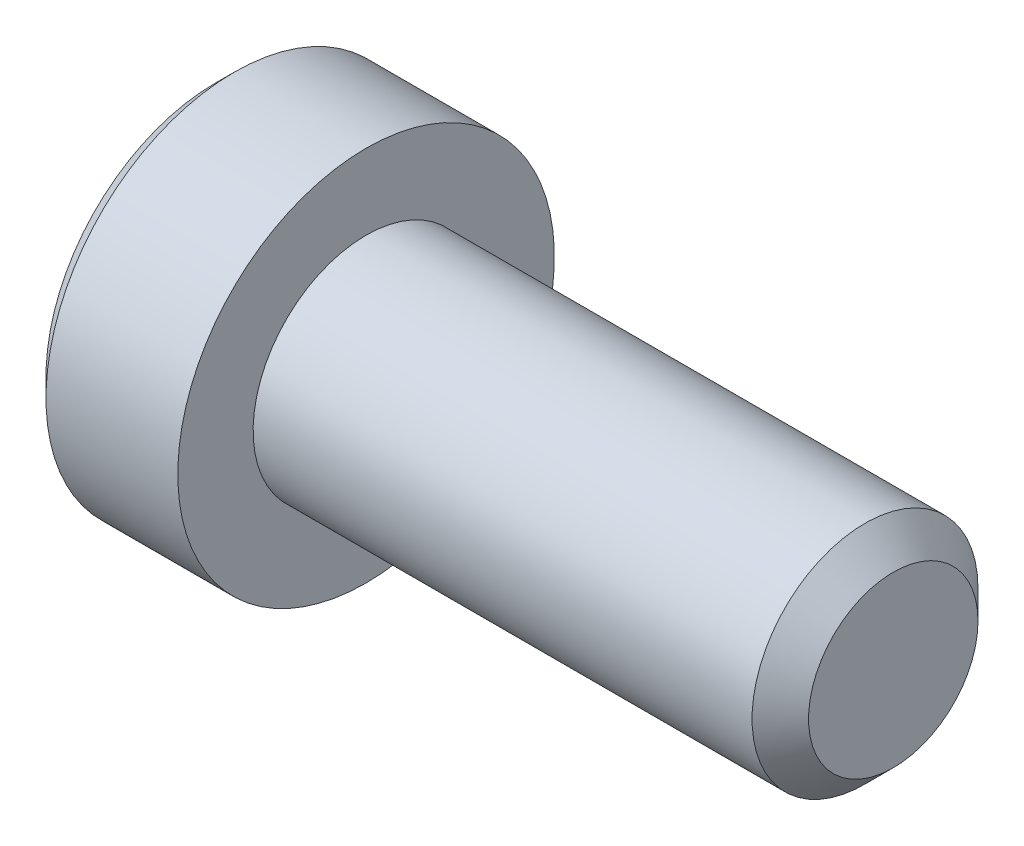
from build123d import *

# Parameters (mm, degrees)
SKETCH2_R           = 3
BOSS_EXTRUDE1_DEPTH = 14
CHAMFER1_SIZE       = 0.75
CUT_EXTRUDE1_DEPTH  = 3.12


with BuildPart() as part:
    # Sketch2 → Boss-Extrude1 (new body)
    with BuildSketch(Plane(origin=(7, 0, 0), x_dir=(0, 0, -1), z_dir=(1, 0, 0))):
        Circle(SKETCH2_R)
    extrude(amount=-BOSS_EXTRUDE1_DEPTH)

    # Chamfer1
    chamfer1_edges = [part.edges().sort_by_distance(p)[0] for p in [
        (7, 0, 3),
    ]]
    chamfer(chamfer1_edges, length=CHAMFER1_SIZE)

    # Sketch6 → Revolve1 (revolve)
    with BuildSketch(Plane.XY):
        Polygon((-10.5, 5), (-11, 4.5), (-11, 0), (-7, 0), (-7, 5), align=None)
    revolve(axis=Axis((-7, 0, 0), (-1, 0, 0)))

    # Sketch4 → Cut-Extrude1 (cut)
    with BuildSketch(Plane(origin=(-11, 0, 0), x_dir=(0, 0, -1), z_dir=(1, 0, 0))):
        Polygon((0, 2.309401077), (-2, 1.154700538), (-2, -1.154700538), (0, -2.309401077), (2, -1.154700538), (2, 1.154700538), align=None)
    extrude(amount=CUT_EXTRUDE1_DEPTH, mode=Mode.SUBTRACT)

    # Cut-Extrude2 cone 1 section (through the dimple's axis) → Cut-Extrude2 (revolve, cut)
    with BuildSketch(Plane(origin=(-11, 0, 0), x_dir=(0, 0, 1), z_dir=(0, 1, 0))):
        Polygon((0, 0), (2.309401077, 0), (0, 2.309401077), align=None)
    revolve(axis=Axis((-11, 0, 0), (1, 0, 0)), mode=Mode.SUBTRACT)


solid = part.part
